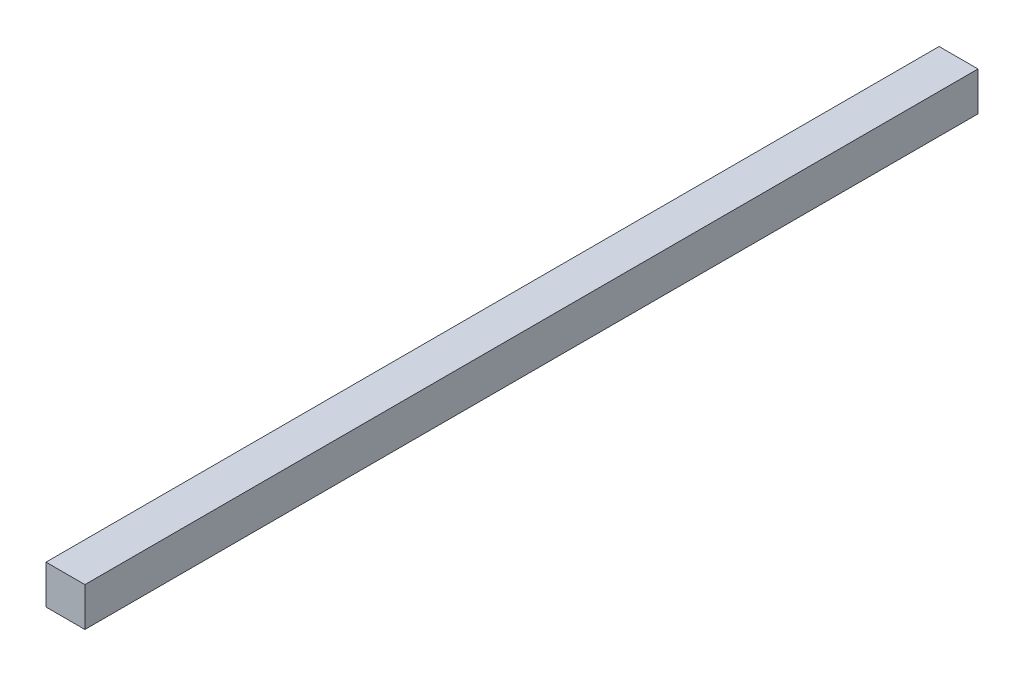
from build123d import *

# Parameters (mm, degrees)
SKETCH1_W           = 10
SKETCH1_H           = 10
BOSS_EXTRUDE1_DEPTH = 229.597


with BuildPart() as part:
    # Sketch1 → Boss-Extrude1 (new body)
    with BuildSketch(Plane.XY):
        Rectangle(SKETCH1_W, SKETCH1_H)
    extrude(amount=BOSS_EXTRUDE1_DEPTH)


solid = part.part
